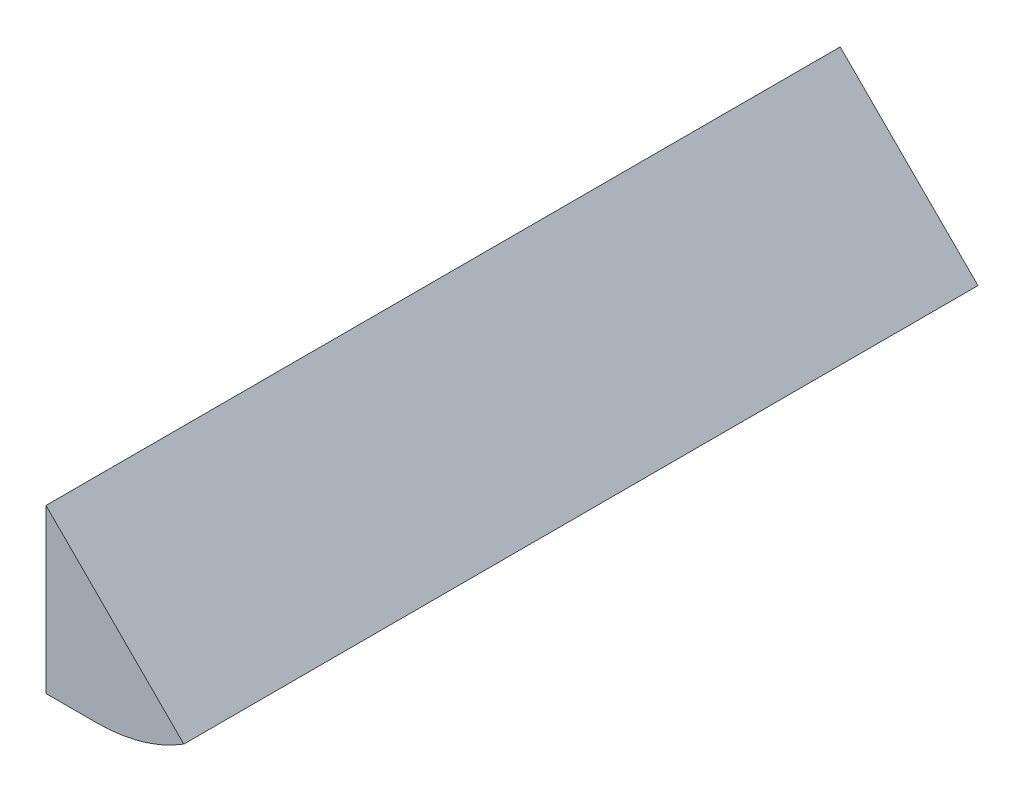
from build123d import *

# Parameters (mm, degrees)
EXTRUDE_START   = -11
EXTRUDE_1_DEPTH = 39


with BuildPart() as part:
    # Эскиз1 → Вытянуть1 (new body)
    with BuildSketch(Plane.XY.offset(EXTRUDE_START)):
        with BuildLine():
            Line((-410, 16), (-410, 8))
            Line((-410, 8), (-407.5, 8.000000243))
            ThreePointArc((-407.5, 8.000000243), (-405.27920659, 8.314424384), (-403.232980944, 9.23298115))
            Line((-403.232980944, 9.23298115), (-410, 16))
        make_face()
    extrude(amount=-EXTRUDE_1_DEPTH)


solid = part.part
